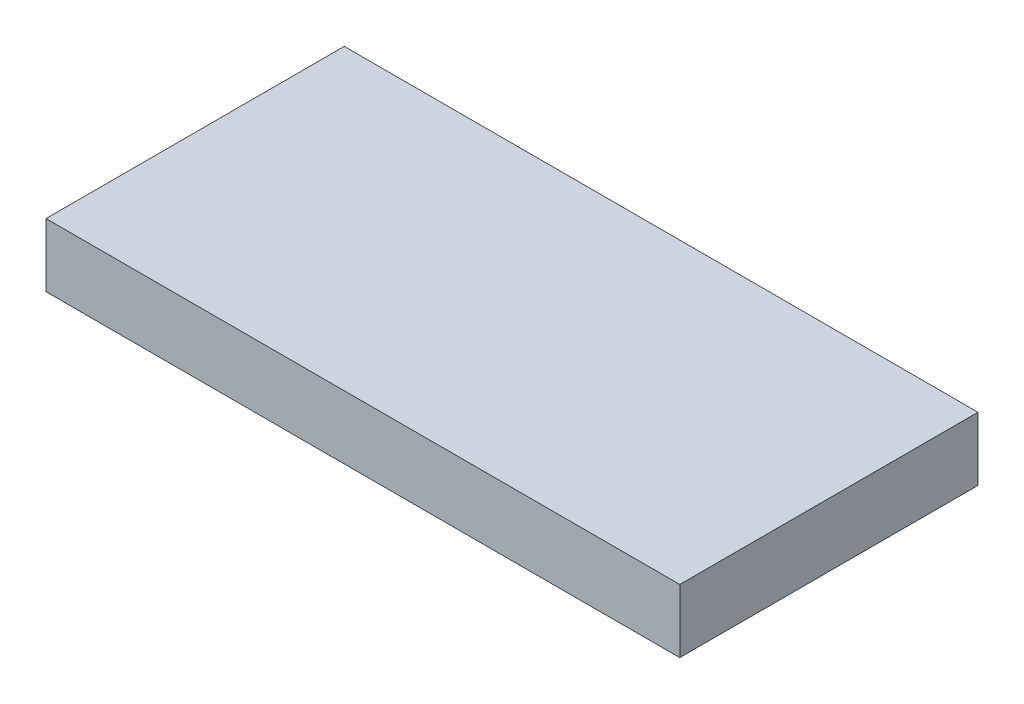
from build123d import *

# Parameters (mm, degrees)
CROQUIS1_W              = 17
CROQUIS1_H              = 8
SALIENTE_EXTRUIR1_DEPTH = 1.7


with BuildPart() as part:
    # Croquis1 → Saliente-Extruir1 (new body)
    with BuildSketch(Plane(origin=(0, 0, 0), x_dir=(1, 0, 0), z_dir=(0, 1, 0))):
        with Locations((-16.061883906, -11.975209045)):
            Rectangle(CROQUIS1_W, CROQUIS1_H)
    extrude(amount=SALIENTE_EXTRUIR1_DEPTH)


solid = part.part
